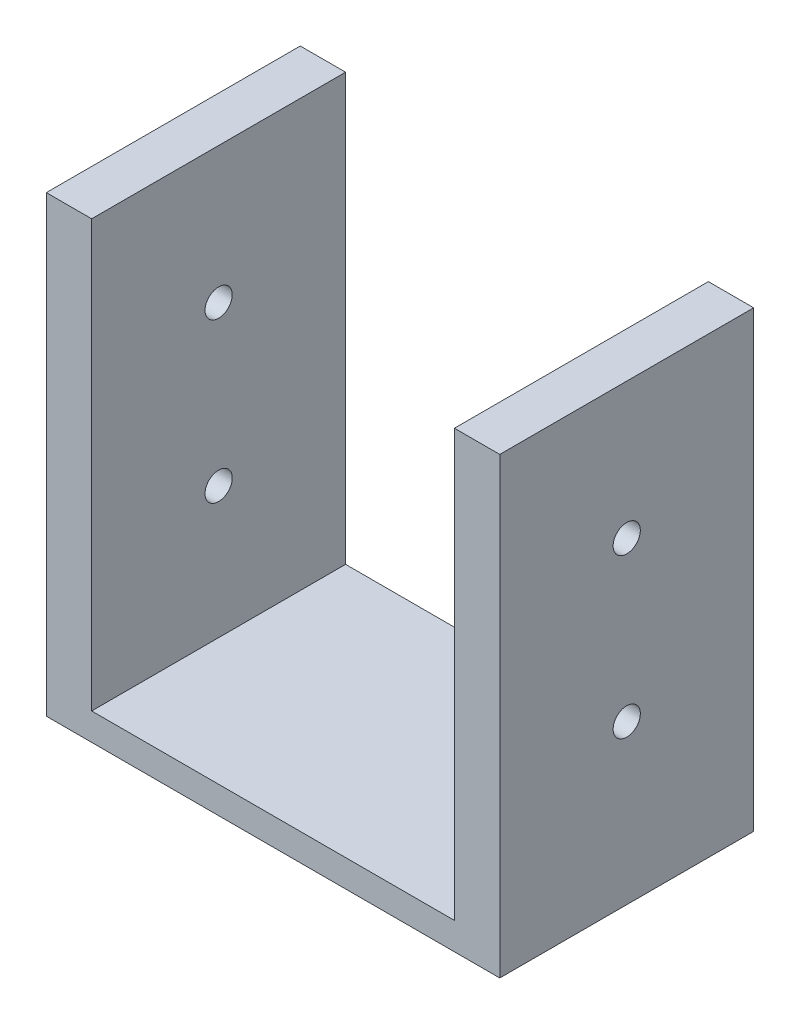
from build123d import *

# Parameters (mm, degrees)
CROQUIS1_W              = 5
CROQUIS1_H              = 28
CROQUIS1_W_2            = 40
SALIENTE_EXTRUIR1_DEPTH = 3
CROQUIS2_W              = 5
CROQUIS2_H              = 28
SALIENTE_EXTRUIR2_DEPTH = 47
CROQUIS3_R              = 1.5
CORTAR_EXTRUIR1_DEPTH   = 51


with BuildPart() as part:
    # Croquis1 → Saliente-Extruir1 (new body)
    with BuildSketch(Plane(origin=(0, 0, 0), x_dir=(1, 0, 0), z_dir=(0, 1, 0))):
        with Locations((-22.5, 0)):
            Rectangle(CROQUIS1_W, CROQUIS1_H)
        Rectangle(CROQUIS1_W_2, CROQUIS1_H)
        with Locations((22.5, 0)):
            Rectangle(CROQUIS1_W, CROQUIS1_H)
    extrude(amount=SALIENTE_EXTRUIR1_DEPTH)

    # Croquis2 → Saliente-Extruir2 (add)
    with BuildSketch(Plane(origin=(0, 3, 0), x_dir=(1, 0, 0), z_dir=(0, 1, 0))):
        with Locations((-22.5, 0)):
            Rectangle(CROQUIS2_W, CROQUIS2_H)
        with Locations((22.5, 0)):
            Rectangle(CROQUIS2_W, CROQUIS2_H)
    extrude(amount=SALIENTE_EXTRUIR2_DEPTH)

    # Croquis3 → Cortar-Extruir1 (cut, through all)
    with BuildSketch(Plane(origin=(25, 0, 0), x_dir=(0, 0, -1), z_dir=(1, 0, 0))):
        with Locations((0, 17.5)):
            Circle(CROQUIS3_R)
        with Locations((0, 35)):
            Circle(CROQUIS3_R)
    extrude(amount=-CORTAR_EXTRUIR1_DEPTH, mode=Mode.SUBTRACT)


solid = part.part
